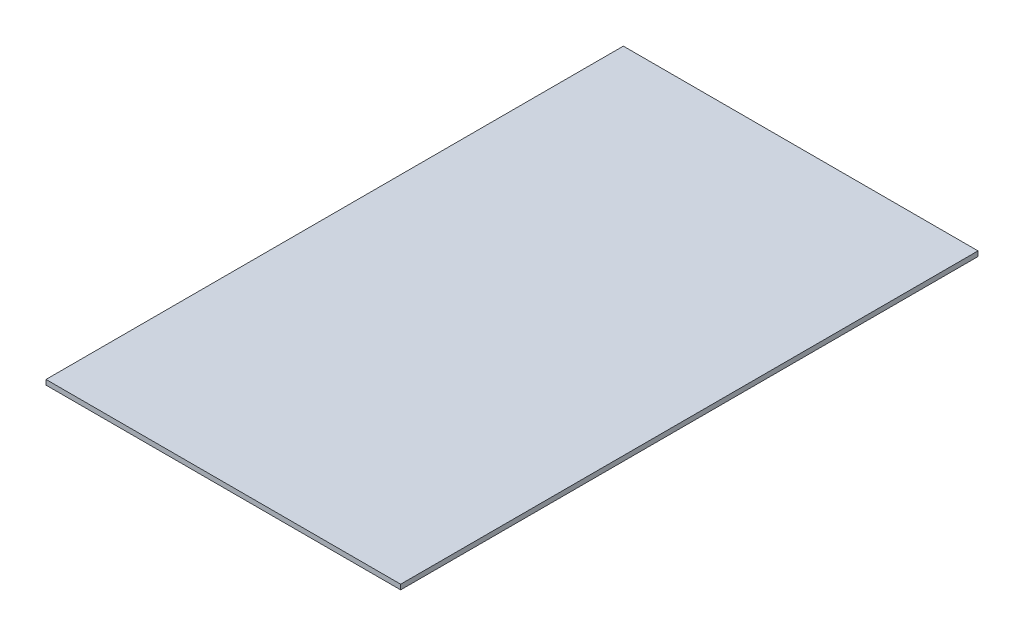
from build123d import *

# Parameters (mm, degrees)
SKETCH1_W           = 215
SKETCH1_H           = 350
BOSS_EXTRUDE1_DEPTH = 3


with BuildPart() as part:
    # Sketch1 → Boss-Extrude1 (new body)
    with BuildSketch(Plane.XZ.offset(10)):
        with Locations((0, 52.5)):
            Rectangle(SKETCH1_W, SKETCH1_H)
    extrude(amount=BOSS_EXTRUDE1_DEPTH)


solid = part.part
